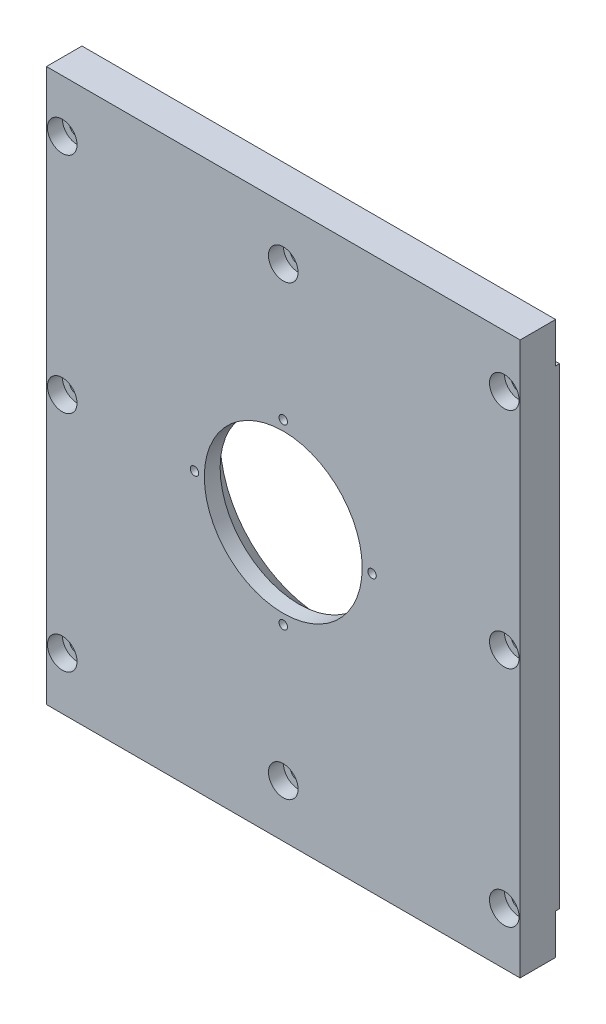
from build123d import *

# Parameters (mm, degrees)
SKETCH1_W                                       = 152.4
SKETCH1_H                                       = 177.8
BOSS_EXTRUDE1_DEPTH                             = 12.7
SKETCH3_R                                       = 25.4
CUT_EXTRUDE2_DEPTH                              = 118.774954893
CBORE_FOR_10_SOCKET_HEAD_CAP_SCREW2_D           = 5.1054
CBORE_FOR_10_SOCKET_HEAD_CAP_SCREW2_CBORE_D     = 9.525
CBORE_FOR_10_SOCKET_HEAD_CAP_SCREW2_CBORE_DEPTH = 4.826
MIRROR5_COPY_1_D                                = 5.1054
MIRROR5_COPY_1_CBORE_D                          = 9.525
MIRROR5_COPY_1_CBORE_DEPTH                      = 4.826
SKETCH21_W                                      = 177.8
SKETCH21_H                                      = 19.05
CUT_EXTRUDE7_DEPTH                              = 1.27
SKETCH22_R                                      = 6.604
CUT_EXTRUDE8_DEPTH                              = 8.89
CIRPATTERN4_COUNT                               = 4
CIRPATTERN5_COUNT                               = 4
CHAMFER1_SIZE                                   = 7.62
CUT_EXTRUDE15_DEPTH                             = 2.032


with BuildPart() as part:
    # Sketch1 → Boss-Extrude1 (new body)
    with BuildSketch(Plane.XY):
        Rectangle(SKETCH1_W, SKETCH1_H)
    extrude(amount=BOSS_EXTRUDE1_DEPTH)

    # Sketch3 → Cut-Extrude2 (cut, through all)
    with BuildSketch(Plane(origin=(0, 0, 0), x_dir=(-1, 0, 0), z_dir=(0, 0, -1))):
        Circle(SKETCH3_R)
    extrude(amount=-CUT_EXTRUDE2_DEPTH, mode=Mode.SUBTRACT)

    # CBORE for #10 Socket Head Cap Screw2 (through all)
    with Locations(Plane.XY.offset(12.7)):
        with Locations((71.12, 72.009), (0, 72.009), (71.12, 0)):
            cbore_for_10_socket_head_cap_screw2 = CounterBoreHole(CBORE_FOR_10_SOCKET_HEAD_CAP_SCREW2_D / 2, CBORE_FOR_10_SOCKET_HEAD_CAP_SCREW2_CBORE_D / 2, CBORE_FOR_10_SOCKET_HEAD_CAP_SCREW2_CBORE_DEPTH)

    # Mirror4: CBORE for #10 Socket Head Cap Screw2 across plane
    add(cbore_for_10_socket_head_cap_screw2.mirror(Plane.ZX), mode=Mode.SUBTRACT)

    # Mirror5: CBORE for #10 Socket Head Cap Screw2 across plane
    add(cbore_for_10_socket_head_cap_screw2.mirror(Plane(origin=(0, 0, 0), x_dir=(0, 0, 1), z_dir=(1, 0, 0))), mode=Mode.SUBTRACT)

    # Mirror5 copy 1 (through all)
    with Locations(Plane(origin=(0, 0, 12.7), x_dir=(-1, 0, 0), z_dir=(0, 0, 1))):
        with Locations((71.12, 72.009), (0, 72.009), (71.12, 0)):
            CounterBoreHole(MIRROR5_COPY_1_D / 2, MIRROR5_COPY_1_CBORE_D / 2, MIRROR5_COPY_1_CBORE_DEPTH)

    # Sketch21 → Cut-Extrude7 (cut)
    with BuildSketch(Plane(origin=(0, 0, 0), x_dir=(-1, 0, 0), z_dir=(0, 0, -1))):
        with Locations((0, 85.471)):
            Rectangle(SKETCH21_W, SKETCH21_H)
    cut_extrude7 = extrude(amount=-CUT_EXTRUDE7_DEPTH, mode=Mode.SUBTRACT)

    # Mirror8: Cut-Extrude7 across plane
    add(cut_extrude7.mirror(Plane.ZX), mode=Mode.SUBTRACT)

    # Sketch22 → Cut-Extrude8 (cut)
    with BuildSketch(Plane(origin=(0, 0, 0), x_dir=(-1, 0, 0), z_dir=(0, 0, -1))):
        with Locations((31.75, 31.75)):
            Circle(SKETCH22_R)
    cut_extrude8 = extrude(amount=-CUT_EXTRUDE8_DEPTH, mode=Mode.SUBTRACT)

    # CirPattern4: Cut-Extrude8 ×4 about axis
    cirpattern4_axis = Axis((0, 0, 0), (0, 0, 1))
    for i in range(1, CIRPATTERN4_COUNT):
        add(cut_extrude8.rotate(cirpattern4_axis, i * 360 / CIRPATTERN4_COUNT), mode=Mode.SUBTRACT)

    # Sketch24 → #6-32 Tapped Hole1 (revolve, cut)
    with BuildSketch(Plane(origin=(0, 28.575, 12.7), x_dir=(0, -1, 0), z_dir=(1, 0, 0))):
        Polygon((0, 0), (0, 5.89269403), (1.35255, 5.08), (1.35255, 0), align=None)
    f_6_32_tapped_hole1 = revolve(axis=Axis((0, 28.575, 19.05), (0, 0, -1)), mode=Mode.SUBTRACT)

    # CirPattern5: #6-32 Tapped Hole1 ×4 about axis
    cirpattern5_axis = Axis((0, 0, 0), (0, 0, 1))
    for i in range(1, CIRPATTERN5_COUNT):
        add(f_6_32_tapped_hole1.rotate(cirpattern5_axis, i * 360 / CIRPATTERN5_COUNT), mode=Mode.SUBTRACT)

    # Chamfer1
    chamfer1_edges = [part.edges().sort_by_distance(p)[0] for p in [
        (25.4, 0, 0),
    ]]
    chamfer(chamfer1_edges, length=CHAMFER1_SIZE)

    # Sketch28 → Cut-Extrude15 (cut)
    with BuildSketch(Plane.XY):
        with BuildLine():
            Line((-62.7507, 67.6275), (62.7507, 67.6275))
            ThreePointArc((62.7507, 67.6275), (66.19911835, 66.19911835), (67.6275, 62.7507))
            Line((67.6275, 62.7507), (67.6275, -62.7507))
            ThreePointArc((67.6275, -62.7507), (66.19911835, -66.19911835), (62.7507, -67.6275))
            Line((62.7507, -67.6275), (-62.7507, -67.6275))
            ThreePointArc((-62.7507, -67.6275), (-66.19911835, -66.19911835), (-67.6275, -62.7507))
            Line((-67.6275, -62.7507), (-67.6275, 62.7507))
            ThreePointArc((-67.6275, 62.7507), (-66.19911835, 66.19911835), (-62.7507, 67.6275))
        make_face()
        with BuildLine():
            Line((-62.7507, 65.2907), (62.7507, 65.2907))
            ThreePointArc((62.7507, 65.2907), (64.546751224, 64.546751224), (65.2907, 62.7507))
            Line((65.2907, 62.7507), (65.2907, -62.7507))
            ThreePointArc((65.2907, -62.7507), (64.546751224, -64.546751224), (62.7507, -65.2907))
            Line((62.7507, -65.2907), (-62.7507, -65.2907))
            ThreePointArc((-62.7507, -65.2907), (-64.546751224, -64.546751224), (-65.2907, -62.7507))
            Line((-65.2907, -62.7507), (-65.2907, 62.7507))
            ThreePointArc((-65.2907, 62.7507), (-64.546751224, 64.546751224), (-62.7507, 65.2907))
        make_face(mode=Mode.SUBTRACT)
    extrude(amount=CUT_EXTRUDE15_DEPTH, mode=Mode.SUBTRACT)


solid = part.part
